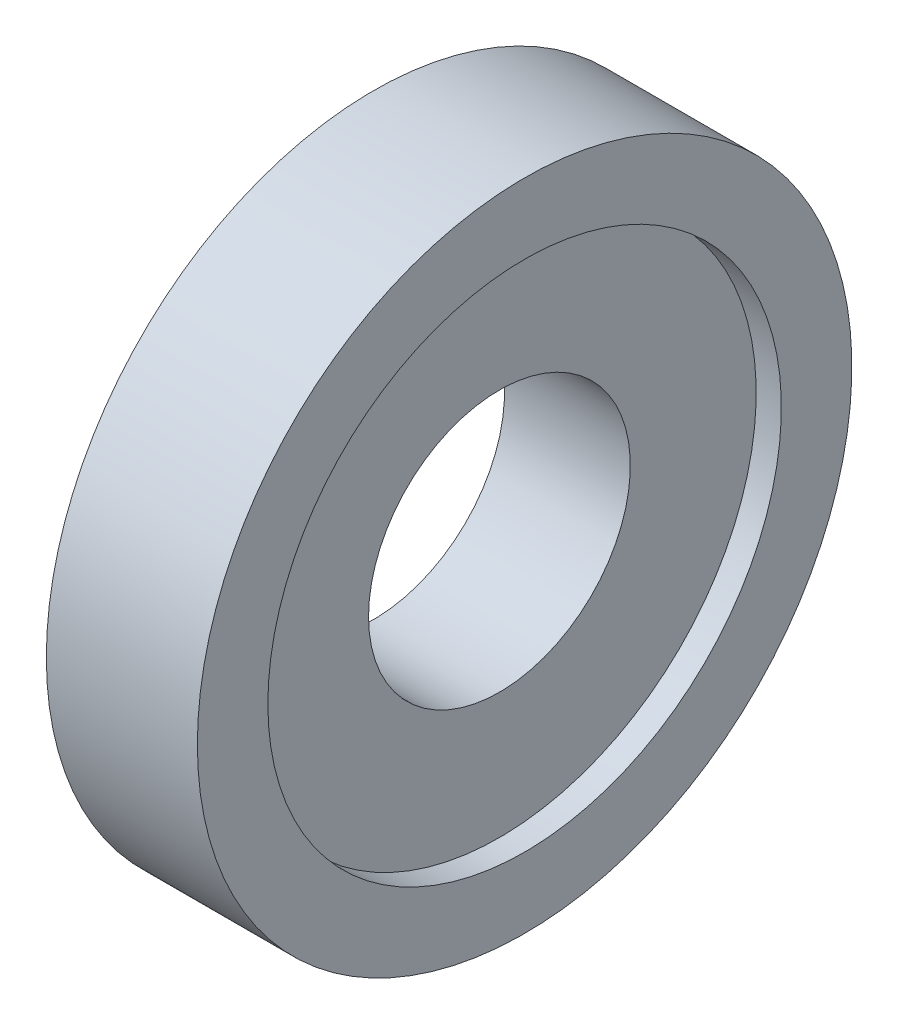
from build123d import *


with BuildPart() as part:
    # 草图1 → 旋转1 (revolve)
    with BuildSketch(Plane.XY):
        Polygon((0, 2.6), (0, 6.5), (3, 6.5), (3, 5.1), (2.5, 5.1), (2.5, 2.6), align=None)
    revolve(axis=Axis((0, 0, 0), (1, 0, 0)))


solid = part.part
